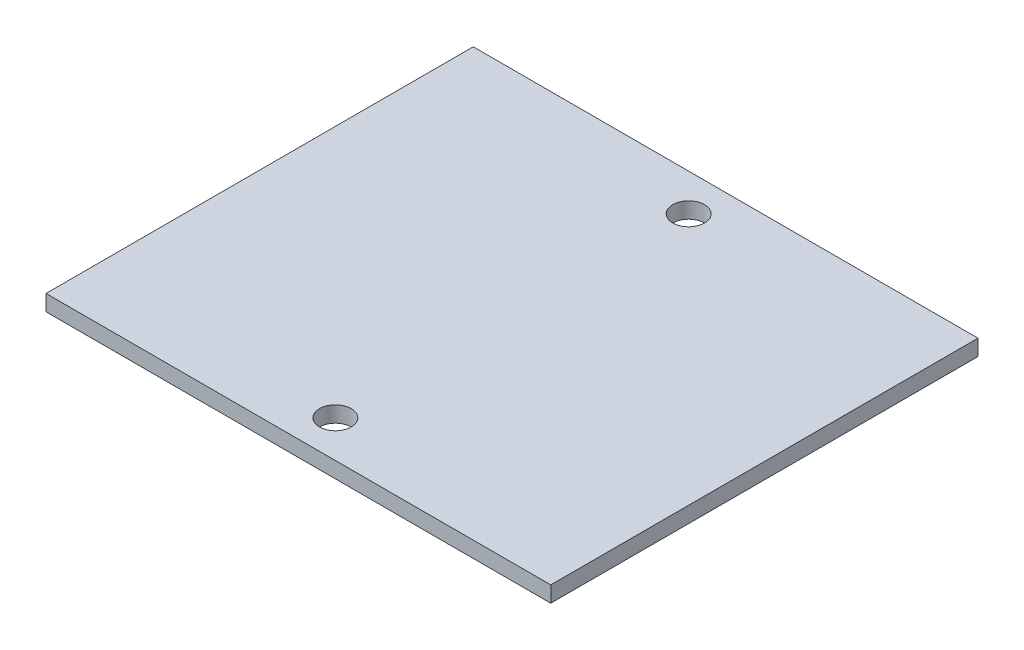
from build123d import *

# Parameters (mm, degrees)
SKETCH1_W           = 50.8
SKETCH1_H           = 43
SKETCH1_R           = 1.599999975
BOSS_EXTRUDE1_DEPTH = 1.6002


with BuildPart() as part:
    # Sketch1 → Boss-Extrude1 (new body)
    with BuildSketch(Plane(origin=(0, 0, 0), x_dir=(1, 0, 0), z_dir=(0, 1, 0))):
        with Locations((25.4, 21.5)):
            Rectangle(SKETCH1_W, SKETCH1_H)
        with Locations((25.4, 39.28)):
            Circle(SKETCH1_R, mode=Mode.SUBTRACT)
        with Locations((25.4, 3.72)):
            Circle(SKETCH1_R, mode=Mode.SUBTRACT)
    extrude(amount=BOSS_EXTRUDE1_DEPTH)


solid = part.part
